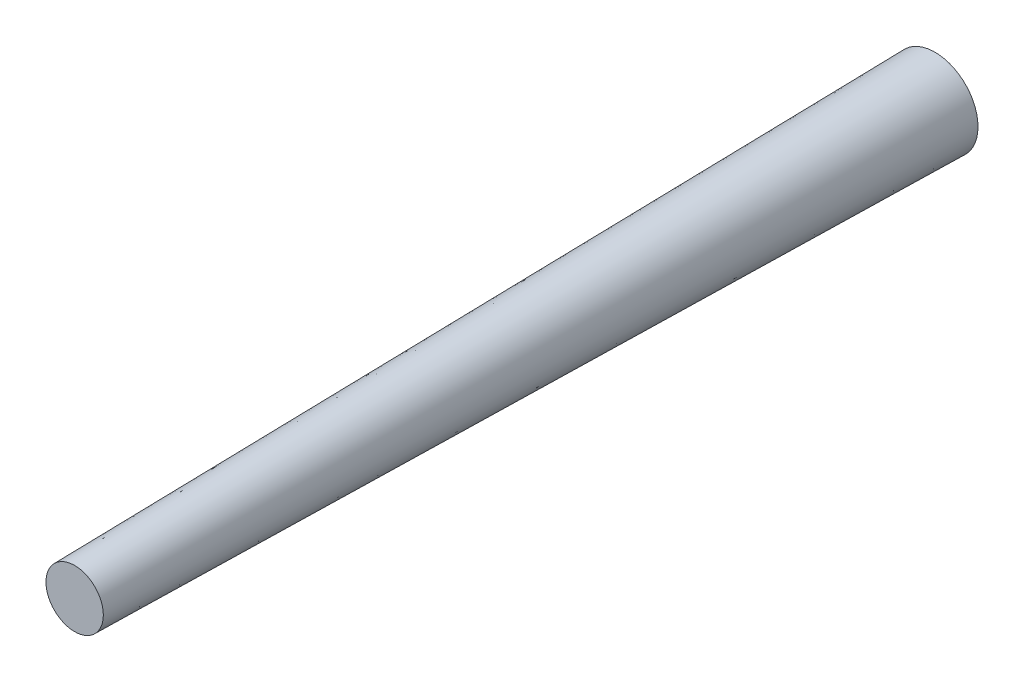
from build123d import *

# Parameters (mm, degrees)
SKETCH1_R           = 3
BOSS_EXTRUDE1_DEPTH = 60
BOSS_EXTRUDE1_TAPER = 0.954


with BuildPart() as part:
    # Sketch1 → Boss-Extrude1 (new body)
    with BuildSketch(Plane.XY):
        Circle(SKETCH1_R)
    extrude(amount=BOSS_EXTRUDE1_DEPTH, taper=BOSS_EXTRUDE1_TAPER)


solid = part.part
